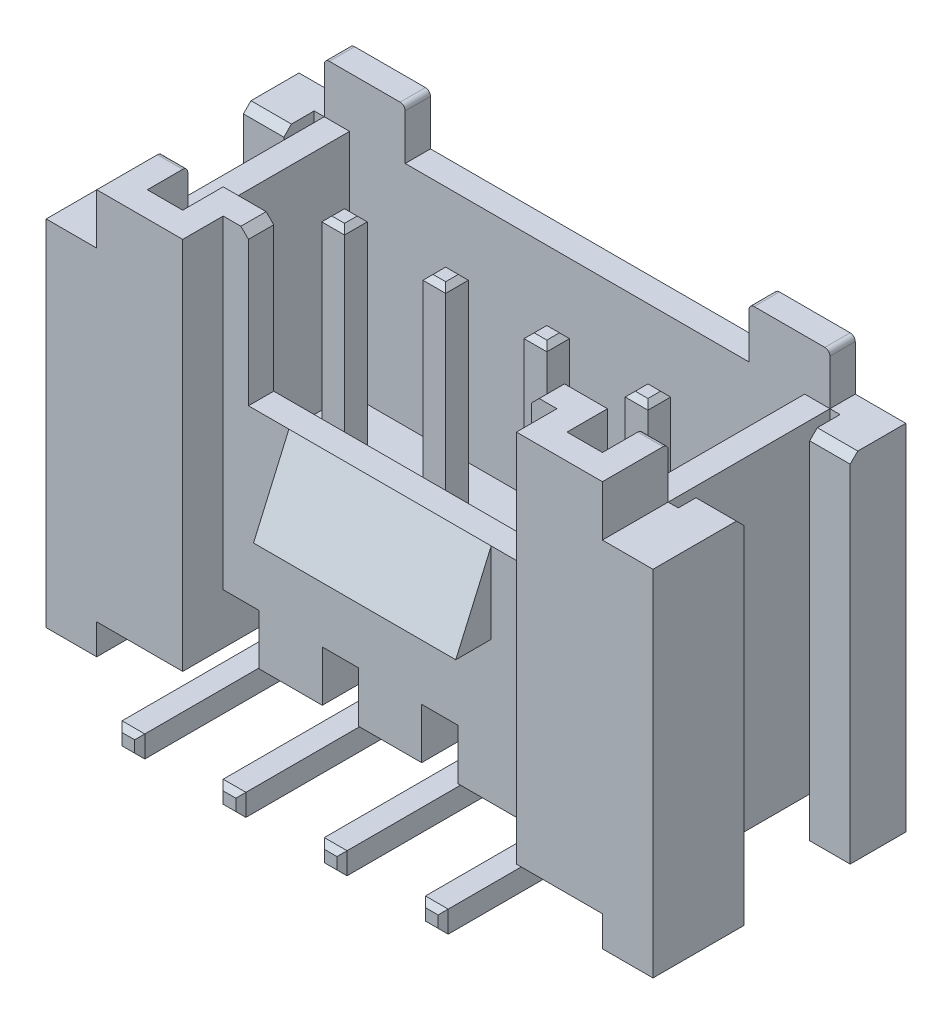
from build123d import *

# Parameters (mm, degrees)
ESQUISSE1_W             = 10
ESQUISSE1_H             = 5
BOSS_EXTRU_1_DEPTH      = 7.4
ESQUISSE2_W             = 6.6
ESQUISSE2_H             = 0.8
ENL_V_MAT_EXTRU_1_DEPTH = 8
ENL_V_MAT_EXTRU_2_DEPTH = 5.5
ESQUISSE5_W             = 6.8
ESQUISSE5_H             = 0.5
ESQUISSE5_W_2           = 0.5
ESQUISSE5_H_2           = 3.2
ENL_V_MAT_EXTRU_3_DEPTH = 1
ESQUISSE6_W             = 5.6
ESQUISSE6_H             = 0.5
ENL_V_MAT_EXTRU_4_DEPTH = 3
ESQUISSE8_W             = 6.6
ESQUISSE8_H             = 4.2
ENL_V_MAT_EXTRU_6_DEPTH = 1
BOSS_EXTRU_2_DEPTH      = 6.8
BOSS_EXTRU_3_DEPTH      = 2
BOSS_EXTRU_3_DEPTH_BACK = 2
ESQUISSE17_W            = 1.25
ESQUISSE17_H            = 4.2
BOSS_EXTRU_8_DEPTH      = 1
CHANFREIN1_SIZE         = 0.15
ESQUISSE13_W            = 0.45
ESQUISSE13_H            = 0.45
BOSS_EXTRU_5_DEPTH      = 0.8
BOSS_EXTRU_5_DEPTH_BACK = 6.3
CONG_2_R                = 0.1
ESQUISSE14_W            = 0.45
ESQUISSE14_H            = 0.43
BOSS_EXTRU_6_DEPTH      = 4.5
CHANFREIN2_SIZE         = 0.1
BOSS_EXTRU_7_DEPTH      = 7
CHANFREIN4_SIZE         = 0.15
CONG_3_R                = 0.1


with BuildPart() as part:
    # Esquisse1 → Boss.-Extru.1 (new body)
    with BuildSketch(Plane(origin=(0, 0, 0), x_dir=(1, 0, 0), z_dir=(0, 1, 0))):
        with Locations((5, 2.5)):
            Rectangle(ESQUISSE1_W, ESQUISSE1_H)
    extrude(amount=BOSS_EXTRU_1_DEPTH)

    # Esquisse2 → Enlèv. mat.-Extru.1 (cut)
    with BuildSketch(Plane(origin=(0, 7.4, 0), x_dir=(1, 0, 0), z_dir=(0, 1, 0))):
        with Locations((5, 0.4)):
            Rectangle(ESQUISSE2_W, ESQUISSE2_H)
    extrude(amount=-ENL_V_MAT_EXTRU_1_DEPTH, mode=Mode.SUBTRACT)

    # Esquisse4 → Enlèv. mat.-Extru.2 (cut)
    with BuildSketch(Plane(origin=(0, 7.4, 0), x_dir=(1, 0, 0), z_dir=(0, 1, 0))):
        Polygon((0.5, 0.5), (1.2, 0.5), (1.2, 1.3), (8.8, 1.3), (8.8, 0.5), (9.5, 0.5), (9.5, 4.5), (0.5, 4.5), align=None)
    extrude(amount=-ENL_V_MAT_EXTRU_2_DEPTH, mode=Mode.SUBTRACT)

    # Esquisse5 → Enlèv. mat.-Extru.3 (cut)
    with BuildSketch(Plane(origin=(0, 7.4, 0), x_dir=(1, 0, 0), z_dir=(0, 1, 0))):
        with Locations((5, 4.75)):
            Rectangle(ESQUISSE5_W, ESQUISSE5_H)
        with Locations((0.25, 2.9)):
            Rectangle(ESQUISSE5_W_2, ESQUISSE5_H_2)
        with Locations((9.75, 2.9)):
            Rectangle(ESQUISSE5_W_2, ESQUISSE5_H_2)
    extrude(amount=-ENL_V_MAT_EXTRU_3_DEPTH, mode=Mode.SUBTRACT)

    # Esquisse6 → Enlèv. mat.-Extru.4 (cut)
    with BuildSketch(Plane(origin=(0, 7.4, 0), x_dir=(1, 0, 0), z_dir=(0, 1, 0))):
        with Locations((5, 1.05)):
            Rectangle(ESQUISSE6_W, ESQUISSE6_H)
    extrude(amount=-ENL_V_MAT_EXTRU_4_DEPTH, mode=Mode.SUBTRACT)

    # Esquisse8 → Enlèv. mat.-Extru.6 (cut)
    with BuildSketch(Plane.XZ):
        with Locations((5, -2.9)):
            Rectangle(ESQUISSE8_W, ESQUISSE8_H)
    extrude(amount=-ENL_V_MAT_EXTRU_6_DEPTH, mode=Mode.SUBTRACT)

    # Esquisse9 → Boss.-Extru.2 (add)
    with BuildSketch(Plane(origin=(1.7, 0, 0), x_dir=(0, 0, -1), z_dir=(1, 0, 0))):
        Polygon((4.7, 1), (3.9, 0.2), (1.9, 0.2), (1.1, 1), align=None)
    extrude(amount=BOSS_EXTRU_2_DEPTH)

    # Esquisse11 → Boss.-Extru.3 (add, two sides)
    with BuildSketch(Plane(origin=(5, 0, 0), x_dir=(0, 0, -1), z_dir=(1, 0, 0))) as boss_extru_3_sk:
        Polygon((0.8, 4.4), (0.1, 2.8), (0.8, 2.8), align=None)
    extrude(amount=BOSS_EXTRU_3_DEPTH)
    extrude(boss_extru_3_sk.sketch, amount=-BOSS_EXTRU_3_DEPTH_BACK)

    # Esquisse17 → Boss.-Extru.8 (add)
    with BuildSketch(Plane(origin=(0, 1, 0), x_dir=(1, 0, 0), z_dir=(0, 1, 0))):
        with Locations((3.035, 2.9)):
            Rectangle(ESQUISSE17_W, ESQUISSE17_H)
        with Locations((5, 2.9)):
            Rectangle(ESQUISSE17_W, ESQUISSE17_H)
        with Locations((6.965, 2.9)):
            Rectangle(ESQUISSE17_W, ESQUISSE17_H)
    extrude(amount=-BOSS_EXTRU_8_DEPTH)

    # Chanfrein1
    chanfrein1_edges = [part.edges().sort_by_distance(p)[0] for p in [
        (2.2, 7.4, -1.05),
        (7.8, 7.4, -1.05),
    ]]
    chamfer(chanfrein1_edges, length=CHANFREIN1_SIZE)

    # Esquisse13 → Boss.-Extru.5 (add, two sides)
    with BuildSketch(Plane.XZ.offset(-0.2)) as boss_extru_5_sk:
        with Locations((8, -2.9)):
            Rectangle(ESQUISSE13_W, ESQUISSE13_H)
        with Locations((4, -2.9)):
            Rectangle(ESQUISSE13_W, ESQUISSE13_H)
        with Locations((2, -2.9)):
            Rectangle(ESQUISSE13_W, ESQUISSE13_H)
        with Locations((6, -2.9)):
            Rectangle(ESQUISSE13_W, ESQUISSE13_H)
    extrude(amount=BOSS_EXTRU_5_DEPTH)
    extrude(boss_extru_5_sk.sketch, amount=-BOSS_EXTRU_5_DEPTH_BACK)

    # Congé2
    cong_2_edges = [part.edges().sort_by_distance(p)[0] for p in [
        (0.25, 7.4, -1.3),
        (0, 7.4, -4.75),
        (1.6, 7.4, -4.75),
        (8.4, 7.4, -4.75),
        (10, 7.4, -4.75),
        (9.75, 7.4, -1.3),
    ]]
    fillet(cong_2_edges, radius=CONG_2_R)

    # Esquisse14 → Boss.-Extru.6 (add)
    with BuildSketch(Plane(origin=(0, 0, -3.125), x_dir=(-1, 0, 0), z_dir=(0, 0, -1))):
        with Locations((-8, -0.385)):
            Rectangle(ESQUISSE14_W, ESQUISSE14_H)
        with Locations((-6, -0.385)):
            Rectangle(ESQUISSE14_W, ESQUISSE14_H)
        with Locations((-4, -0.385)):
            Rectangle(ESQUISSE14_W, ESQUISSE14_H)
        with Locations((-2, -0.385)):
            Rectangle(ESQUISSE14_W, ESQUISSE14_H)
    extrude(amount=-BOSS_EXTRU_6_DEPTH)

    # Chanfrein2
    chanfrein2_edges = [part.edges().sort_by_distance(p)[0] for p in [
        (4.225, 6.5, -2.9),
        (4, 6.5, -3.125),
        (3.775, 6.5, -2.9),
        (4, 6.5, -2.675),
        (2.225, 6.5, -2.9),
        (2, 6.5, -3.125),
        (1.775, 6.5, -2.9),
        (2, 6.5, -2.675),
        (8, 6.5, -3.125),
        (7.775, 6.5, -2.9),
        (8, 6.5, -2.675),
        (8.225, 6.5, -2.9),
        (6, 6.5, -3.125),
        (5.775, 6.5, -2.9),
        (6, 6.5, -2.675),
        (6.225, 6.5, -2.9),
        (8.225, -0.385, 1.375),
        (8, -0.17, 1.375),
        (7.775, -0.385, 1.375),
        (8, -0.6, 1.375),
        (6.225, -0.385, 1.375),
        (6, -0.17, 1.375),
        (5.775, -0.385, 1.375),
        (6, -0.6, 1.375),
        (4.225, -0.385, 1.375),
        (4, -0.17, 1.375),
        (3.775, -0.385, 1.375),
        (4, -0.6, 1.375),
        (2.225, -0.385, 1.375),
        (2, -0.17, 1.375),
        (1.775, -0.385, 1.375),
        (2, -0.6, 1.375),
    ]]
    chamfer(chanfrein2_edges, length=CHANFREIN2_SIZE)

    # Esquisse16 → Boss.-Extru.7 (add)
    with BuildSketch(Plane(origin=(0, 6.4, 0), x_dir=(1, 0, 0), z_dir=(0, 1, 0))):
        Polygon((0, 1.3), (-0.2, 1.3), (-0.2, 1.8), (-1, 1.8), (-1, 1.3), (-1, 0), (0, 0), align=None)
        Polygon((-0.2, 4.5), (-0.2, 3.9), (-1, 3.9), (-1, 5), (-0.2, 5), (0, 5), (0, 4.5), align=None)
        Polygon((11, 3.9), (10.2, 3.9), (10.2, 4.5), (10, 4.5), (10, 5), (10.2, 5), (11, 5), align=None)
        Polygon((11, 1.3), (11, 1.8), (10.2, 1.8), (10.2, 1.3), (10, 1.3), (10, 0), (11, 0), align=None)
    extrude(amount=-BOSS_EXTRU_7_DEPTH)

    # Chanfrein4
    chanfrein4_edges = [part.edges().sort_by_distance(p)[0] for p in [
        (-0.6, 6.4, -1.8),
        (-0.6, 6.4, -3.9),
        (10.6, 6.4, -3.9),
        (10.6, 6.4, -1.8),
    ]]
    chamfer(chanfrein4_edges, length=CHANFREIN4_SIZE)

    # Congé3
    cong_3_edges = [part.edges().sort_by_distance(p)[0] for p in [
        (4, -0.6, -3.125),
        (2, -0.6, -3.125),
        (8, -0.6, -3.125),
        (6, -0.6, -3.125),
        (8, -0.17, -2.675),
        (6, -0.17, -2.675),
        (4, -0.17, -2.675),
        (2, -0.17, -2.675),
    ]]
    fillet(cong_3_edges, radius=CONG_3_R)


solid = part.part
